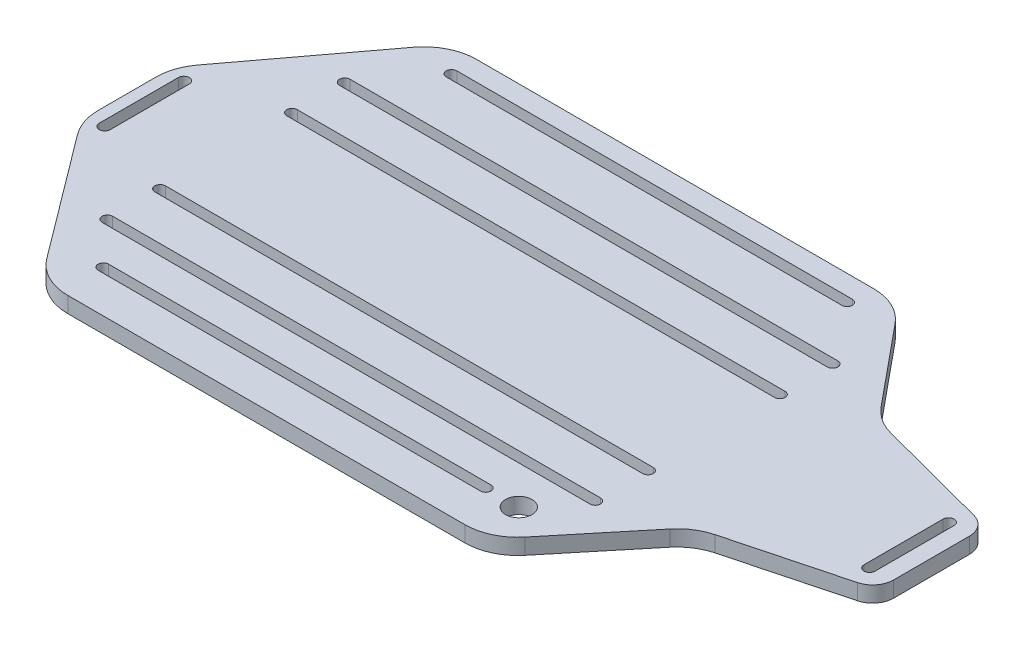
from build123d import *

# Parameters (mm, degrees)
BOSS_EXTRUDE2_DEPTH = 6
SKETCH2_R           = 5
CUT_EXTRUDE2_DEPTH  = 6


with BuildPart() as part:
    # Sketch1 → Boss-Extrude2 (new body)
    with BuildSketch(Plane(origin=(0, 0, 0), x_dir=(1, 0, 0), z_dir=(0, 1, 0))):
        with BuildLine():
            Line((-91, -69.5), (-126, -22.833333333))
            ThreePointArc((-126, -22.833333333), (-128.973665961, -17.157888654), (-130, -10.833333333))
            Line((-130, -10.833333333), (-130, 10.833333333))
            ThreePointArc((-130, 10.833333333), (-128.973665961, 17.157888654), (-126, 22.833333333))
            Line((-126, 22.833333333), (-91, 69.5))
            ThreePointArc((-91, 69.5), (-83.94427191, 75.38854382), (-75, 77.5))
            Line((-75, 77.5), (75.561511123, 77.5))
            ThreePointArc((75.561511123, 77.5), (84.097233086, 75.587052014), (91.000115835, 70.214145057))
            Line((91.000115835, 70.214145057), (115.898546704, 39.980336145))
            ThreePointArc((115.898546704, 39.980336145), (120.54751552, 35.854535916), (126.238632031, 33.355269737))
            Line((126.238632031, 33.355269737), (169.039407754, 22.071428865))
            ThreePointArc((169.039407754, 22.071428865), (173.337004893, 19.218609112), (175, 14.335744279))
            Line((175, 14.335744279), (175, -14.335744279))
            ThreePointArc((175, -14.335744279), (173.337004893, -19.218609112), (169.039407754, -22.071428865))
            Line((169.039407754, -22.071428865), (126.238632031, -33.355269737))
            ThreePointArc((126.238632031, -33.355269737), (120.54751552, -35.854535916), (115.898546704, -39.980336145))
            Line((115.898546704, -39.980336145), (91.000115835, -70.214145057))
            ThreePointArc((91.000115835, -70.214145057), (84.097233086, -75.587052014), (75.561511123, -77.5))
            Line((75.561511123, -77.5), (-75, -77.5))
            ThreePointArc((-75, -77.5), (-83.94427191, -75.38854382), (-91, -69.5))
        make_face()
    extrude(amount=BOSS_EXTRUDE2_DEPTH)

    # Sketch2 → Cut-Extrude2 (cut)
    with BuildSketch(Plane(origin=(0, 6, 0), x_dir=(1, 0, 0), z_dir=(0, 1, 0))):
        with Locations((80, -61.5)):
            Circle(SKETCH2_R)
        with BuildLine():
            Line((168.6, 15), (168.6, -15))
            ThreePointArc((168.6, -15), (166.5, -17.1), (164.4, -15))
            Line((164.4, -15), (164.4, 15))
            ThreePointArc((164.4, 15), (166.5, 17.1), (168.6, 15))
        make_face()
        with BuildLine():
            Line((-121.4, 15), (-121.4, -15))
            ThreePointArc((-121.4, -15), (-123.5, -17.1), (-125.6, -15))
            Line((-125.6, -15), (-125.6, 15))
            ThreePointArc((-125.6, 15), (-123.5, 17.1), (-121.4, 15))
        make_face()
        with BuildLine():
            Line((-92.5, 47), (92.5, 47))
            ThreePointArc((92.5, 47), (94.5, 45), (92.5, 43))
            Line((92.5, 43), (-92.5, 43))
            ThreePointArc((-92.5, 43), (-94.5, 45), (-92.5, 47))
        make_face()
        with BuildLine():
            Line((-92.5, -43), (92.5, -43))
            ThreePointArc((92.5, -43), (94.5, -45), (92.5, -47))
            Line((92.5, -47), (-92.5, -47))
            ThreePointArc((-92.5, -47), (-94.5, -45), (-92.5, -43))
        make_face()
        with BuildLine():
            Line((-92.5, 27), (92.5, 27))
            ThreePointArc((92.5, 27), (94.5, 25), (92.5, 23))
            Line((92.5, 23), (-92.5, 23))
            ThreePointArc((-92.5, 23), (-94.5, 25), (-92.5, 27))
        make_face()
        with BuildLine():
            Line((-92.5, -23), (92.5, -23))
            ThreePointArc((92.5, -23), (94.5, -25), (92.5, -27))
            Line((92.5, -27), (-92.5, -27))
            ThreePointArc((-92.5, -27), (-94.5, -25), (-92.5, -23))
        make_face()
        with BuildLine():
            Line((-75, 70), (75, 70))
            ThreePointArc((75, 70), (77, 68), (75, 66))
            Line((75, 66), (-75, 66))
            ThreePointArc((-75, 66), (-77, 68), (-75, 70))
        make_face()
        with BuildLine():
            Line((-77.53734134, -59.5), (67.46265866, -59.5))
            ThreePointArc((67.46265866, -59.5), (69.46265866, -61.5), (67.46265866, -63.5))
            Line((67.46265866, -63.5), (-77.53734134, -63.5))
            ThreePointArc((-77.53734134, -63.5), (-79.53734134, -61.5), (-77.53734134, -59.5))
        make_face()
    extrude(amount=-CUT_EXTRUDE2_DEPTH, mode=Mode.SUBTRACT)


solid = part.part
